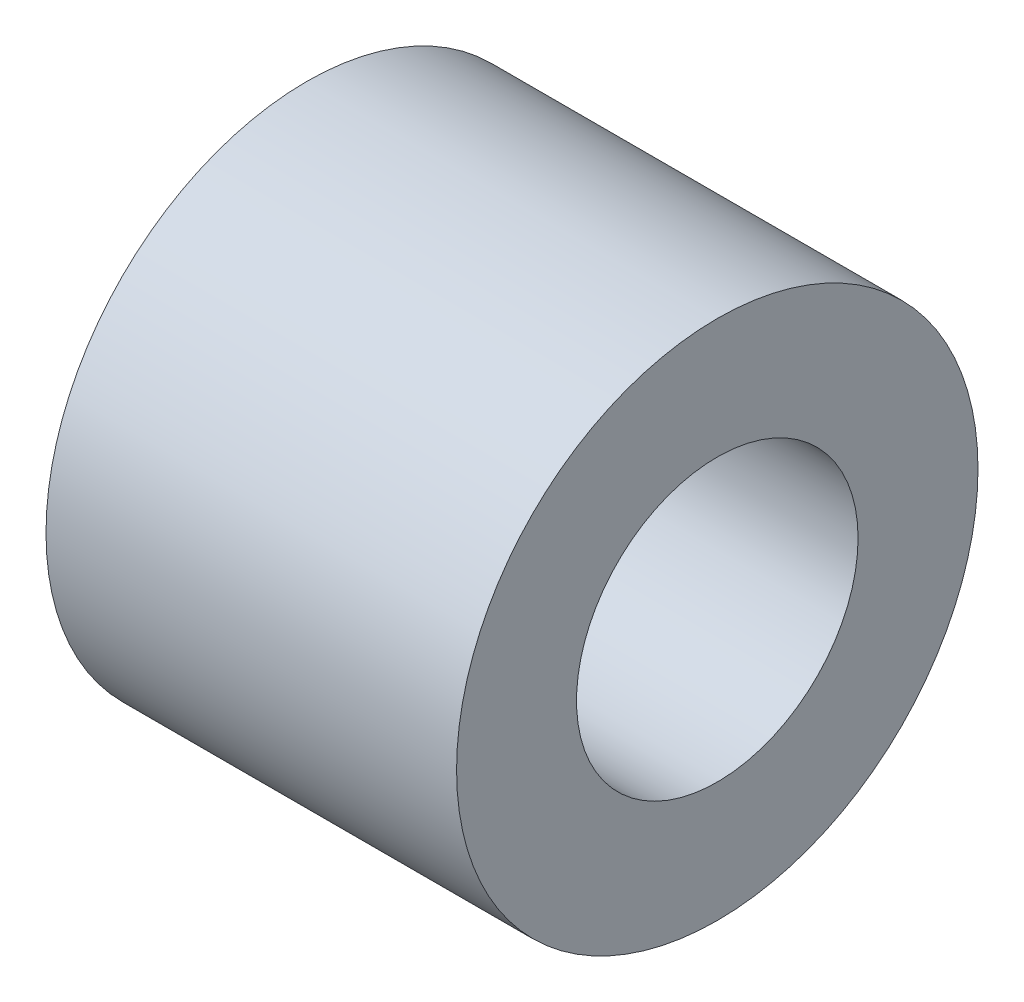
from build123d import *

# Parameters (mm, degrees)
ESQUISSE1_R        = 6.35
ESQUISSE1_R_2      = 3.429
BOSS_EXTRU_1_DEPTH = 10


with BuildPart() as part:
    # Esquisse1 → Boss.-Extru.1 (new body)
    with BuildSketch(Plane(origin=(0, 0, 0), x_dir=(0, 0, -1), z_dir=(1, 0, 0))):
        Circle(ESQUISSE1_R)
        Circle(ESQUISSE1_R_2, mode=Mode.SUBTRACT)
    extrude(amount=-BOSS_EXTRU_1_DEPTH)


solid = part.part
